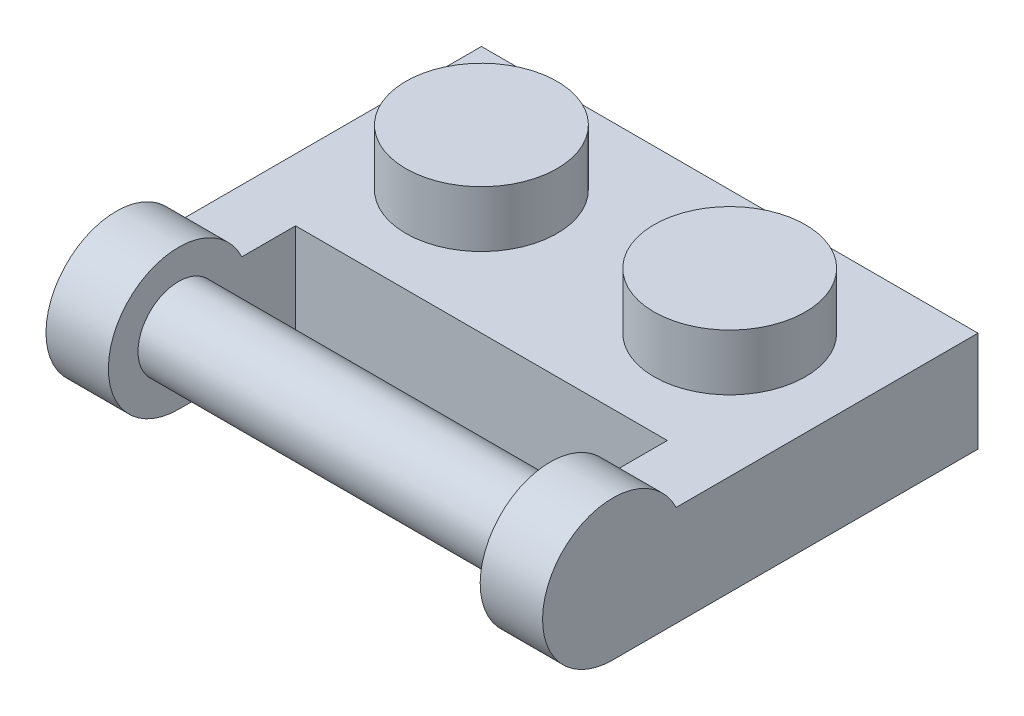
from build123d import *

# Parameters (mm, degrees)
SKETCH1_W       = 7.96
SKETCH1_H       = 7.96
EXTRUDE1_DEPTH  = 3.22
SKETCH2_R       = 2.425
EXTRUDE2_DEPTH  = 1.8
LPATTERN1_COUNT = 2
LPATTERN1_PITCH = 7.96
SHELL1_T        = -1.55
SKETCH4_W       = 12.82
SKETCH4_H       = 4.86
EXTRUDE3_DEPTH  = 0.14
SKETCH5_R       = 1.5
SKETCH5_R_2     = 0.64
EXTRUDE4_DEPTH  = 1.81
EXTRUDE5_DEPTH  = 2
EXTRUDE6_DEPTH  = 2
SKETCH8_R       = 1.3
EXTRUDE7_DEPTH  = 15.92


with BuildPart() as part:
    # Sketch1 → Extrude1 (new body)
    with BuildSketch(Plane(origin=(0, 0, 0), x_dir=(1, 0, 0), z_dir=(0, 1, 0))):
        Rectangle(SKETCH1_W, SKETCH1_H)
    extrude1 = extrude(amount=EXTRUDE1_DEPTH)

    # Sketch2 → Extrude2 (add)
    with BuildSketch(Plane(origin=(0, 3.22, 0), x_dir=(1, 0, 0), z_dir=(0, 1, 0))):
        Circle(SKETCH2_R)
    extrude2 = extrude(amount=EXTRUDE2_DEPTH)

    # LPattern1: Extrude1, Extrude2 ×2
    with Locations(*[(i * LPATTERN1_PITCH, 0, 0) for i in range(1, LPATTERN1_COUNT)]):
        add(extrude1)
        add(extrude2)

    # Shell1
    shell1_openings = [part.faces().sort_by_distance(p)[0] for p in [
        (3.98, 0, 0),
    ]]
    offset(amount=SHELL1_T, openings=shell1_openings, kind=Kind.INTERSECTION)

    # Sketch4 → Extrude3 (cut)
    with BuildSketch(Plane.XZ.offset(-1.67)):
        with Locations((3.98, 0)):
            Rectangle(SKETCH4_W, SKETCH4_H)
    extrude(amount=-EXTRUDE3_DEPTH, mode=Mode.SUBTRACT)

    # Sketch5 → Extrude4 (add)
    with BuildSketch(Plane.XZ.offset(-1.81)):
        with Locations((3.98, 0)):
            Circle(SKETCH5_R)
        with Locations((3.98, 0)):
            Circle(SKETCH5_R_2, mode=Mode.SUBTRACT)
    extrude(amount=EXTRUDE4_DEPTH)

    # Sketch6 → Extrude5 (add)
    with BuildSketch(Plane(origin=(11.94, 0, 0), x_dir=(0, 0, -1), z_dir=(1, 0, 0))):
        with BuildLine():
            Line((-7.73, 0), (-3.98, 0))
            Line((-3.98, 0), (-3.98, 3.22))
            Line((-3.98, 3.22), (-5.699827594, 3.22))
            ThreePointArc((-5.699827594, 3.22), (-9.633286631, 3.45), (-7.73, 0))
        make_face()
    extrude(amount=-EXTRUDE5_DEPTH)

    # Sketch7 → Extrude6 (add)
    with BuildSketch(Plane.ZY.offset(3.98)):
        with BuildLine():
            Line((3.98, 3.22), (3.98, 0))
            Line((3.98, 0), (7.73, 0))
            ThreePointArc((7.73, 0), (9.633286631, 3.45), (5.699827594, 3.22))
            Line((5.699827594, 3.22), (3.98, 3.22))
        make_face()
    extrude(amount=-EXTRUDE6_DEPTH)

    # Sketch8 → Extrude7 (add)
    with BuildSketch(Plane.ZY.offset(3.98)):
        with Locations((7.73, 2.25)):
            Circle(SKETCH8_R)
    extrude(amount=-EXTRUDE7_DEPTH)


solid = part.part
